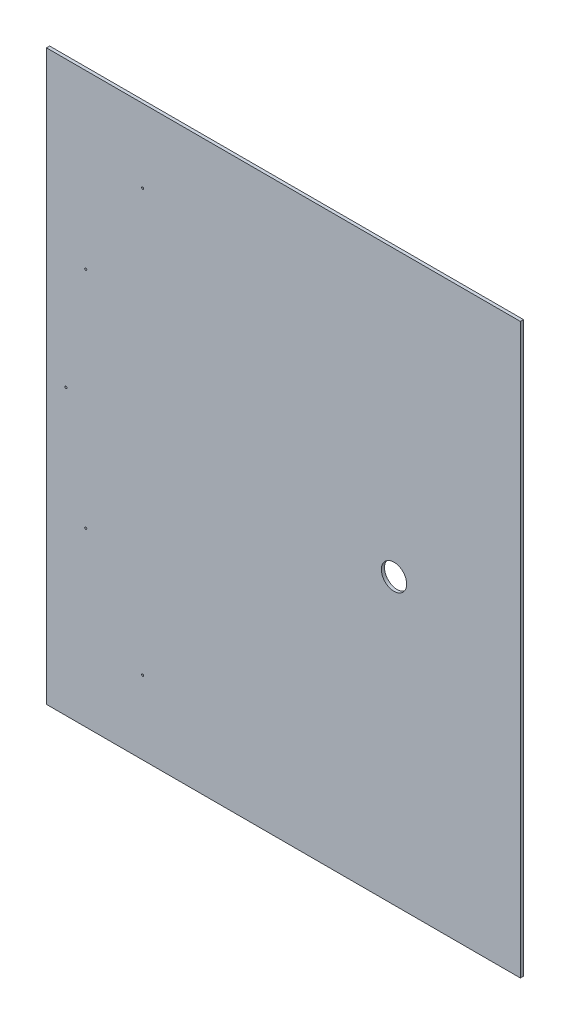
from build123d import *

# Parameters (mm, degrees)
ESBO_O1_W                = 1500
ESBO_O1_H                = 1800
RESSALTO_EXTRUS_O1_DEPTH = 10
ESBO_O2_R                = 40
CORTE_EXTRUS_O1_DEPTH    = 11
FURO_COM_FOLGA_DE_M61_D  = 6.6


with BuildPart() as part:
    # Esboço1 → Ressalto-extrusão1 (new body)
    with BuildSketch(Plane.XY):
        Rectangle(ESBO_O1_W, ESBO_O1_H)
    extrude(amount=RESSALTO_EXTRUS_O1_DEPTH)

    # Esboço2 → Corte-extrusão1 (cut, through all)
    with BuildSketch(Plane.XY.offset(10)):
        with Locations((350, 0)):
            Circle(ESBO_O2_R)
    extrude(amount=-CORTE_EXTRUS_O1_DEPTH, mode=Mode.SUBTRACT)

    # Furo com folga de M61 (through all)
    with Locations(Plane(origin=(350, 0, 16), x_dir=(0, 1, 0), z_dir=(0, 0, 1))):
        with Locations((0, 1038.39252282), (355.151159483, 975.769791173), (667.46584766, 795.454821883), (-355.151159483, 975.769791173), (-667.46584766, 795.454821883)):
            Hole(FURO_COM_FOLGA_DE_M61_D / 2)


solid = part.part
